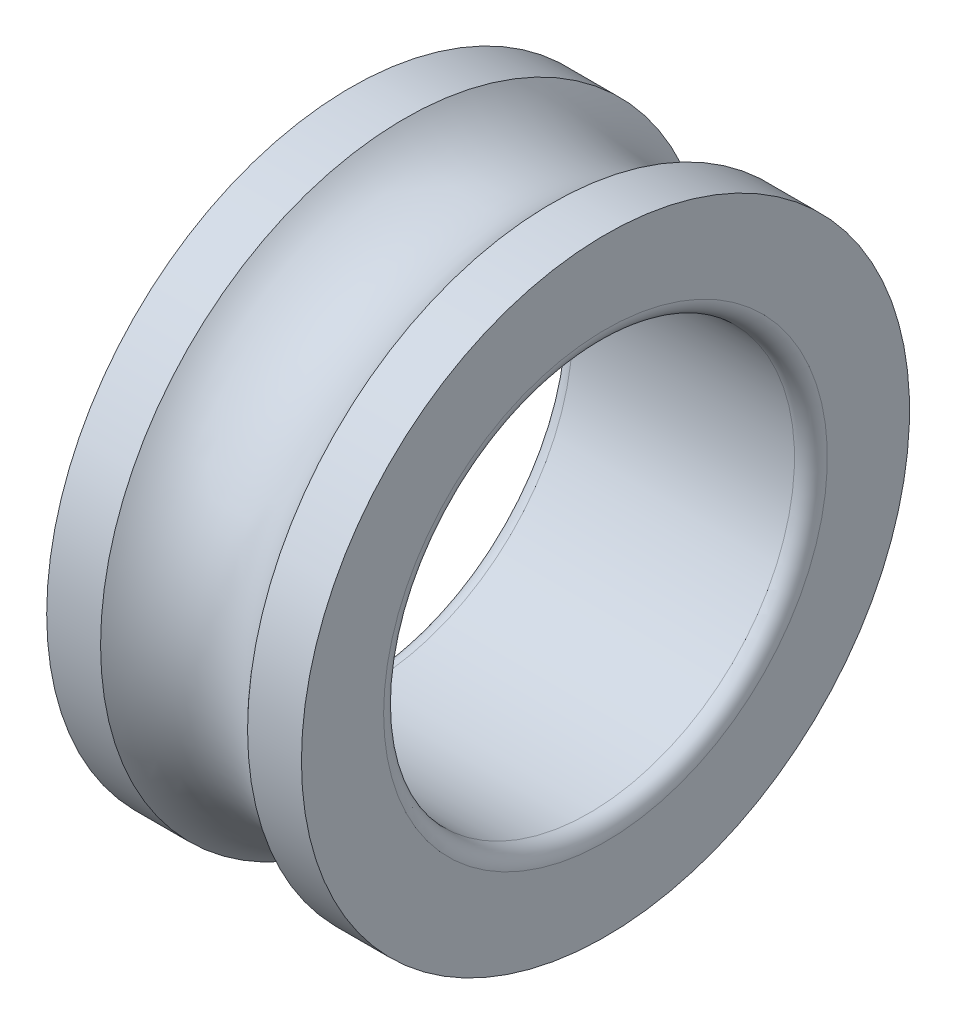
from build123d import *


with BuildPart() as part:
    # Sketch1 → Revolve1 (revolve)
    with BuildSketch(Plane.XY):
        with BuildLine():
            Line((13.5, 25), (-13.5, 25))
            ThreePointArc((-13.5, 25), (-14.914213562, 25.585786438), (-15.5, 27))
            Line((-15.5, 27), (-15.5, 37))
            Line((-15.5, 37), (-8.94427191, 37))
            ThreePointArc((-8.94427191, 37), (0, 33), (8.94427191, 37))
            Line((8.94427191, 37), (15.5, 37))
            Line((15.5, 37), (15.5, 27))
            ThreePointArc((15.5, 27), (14.914213562, 25.585786438), (13.5, 25))
        make_face()
    revolve(axis=Axis((-15.5, 0, 0), (1, 0, 0)))


solid = part.part
